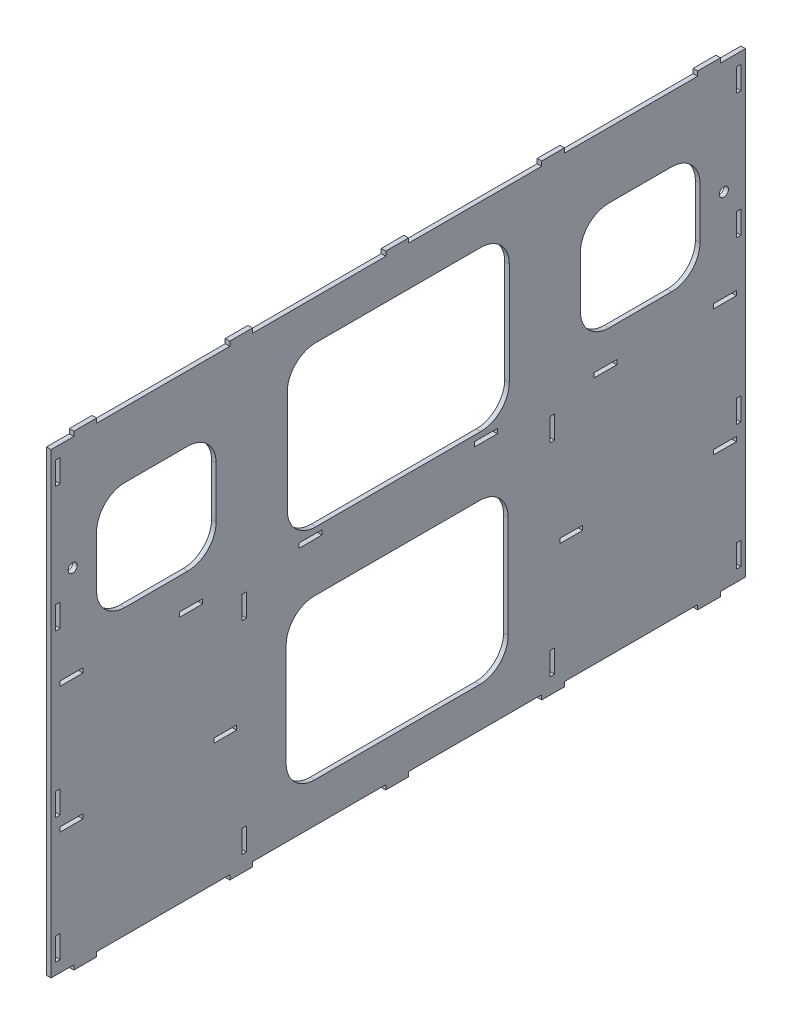
from build123d import *

# Parameters (mm, degrees)
SKETCH1_W           = 20
SKETCH1_H           = 4
SKETCH1_W_2         = 4
SKETCH1_H_2         = 20
BOSS_EXTRUDE1_DEPTH = 4
CUT_EXTRUDE1_DEPTH  = 10
SKETCH3_R           = 4
CUT_EXTRUDE2_DEPTH  = 10


with BuildPart() as part:
    # Sketch1 → Boss-Extrude1 (new body)
    with BuildSketch(Plane(origin=(0, 0, 0), x_dir=(0, 0, -1), z_dir=(1, 0, 0))):
        Polygon((-401.564712347, -166), (-381.564712347, -166), (-381.564712347, -170), (-361.564712347, -170), (-361.564712347, -166), (-244.564712347, -166), (-244.564712347, -170), (-224.564712347, -170), (-224.564712347, -166), (-107.564712347, -166), (-107.564712347, -170), (-87.564712347, -170), (-87.564712347, -166), (29.435287653, -166), (29.435287653, -170), (49.435287653, -170), (49.435287653, -166), (166.435287653, -166), (166.435287653, -170), (186.435287653, -170), (186.435287653, -166), (208.435287653, -166), (208.435287653, 236), (186.435287653, 236), (186.435287653, 240), (166.435287653, 240), (166.435287653, 236), (49.435287653, 236), (49.435287653, 240), (29.435287653, 240), (29.435287653, 236), (-87.564712347, 236), (-87.564712347, 240), (-107.564712347, 240), (-107.564712347, 236), (-224.564712347, 236), (-224.564712347, 240), (-244.564712347, 240), (-244.564712347, 236), (-361.564712347, 236), (-361.564712347, 240), (-381.564712347, 240), (-381.564712347, 236), (-401.564712347, 236), align=None)
        with Locations((190.435287653, -57)):
            Rectangle(SKETCH1_W, SKETCH1_H, mode=Mode.SUBTRACT)
        with Locations((38.825287653, 32)):
            Rectangle(SKETCH1_W_2, SKETCH1_H_2, mode=Mode.SUBTRACT)
        with Locations((38.825287653, -146)):
            Rectangle(SKETCH1_W_2, SKETCH1_H_2, mode=Mode.SUBTRACT)
        with Locations((-395.564712347, 216)):
            Rectangle(SKETCH1_W_2, SKETCH1_H_2, mode=Mode.SUBTRACT)
        with Locations((-395.564712347, 106)):
            Rectangle(SKETCH1_W_2, SKETCH1_H_2, mode=Mode.SUBTRACT)
        with Locations((-395.564712347, -36)):
            Rectangle(SKETCH1_W_2, SKETCH1_H_2, mode=Mode.SUBTRACT)
        with Locations((-395.564712347, -146)):
            Rectangle(SKETCH1_W_2, SKETCH1_H_2, mode=Mode.SUBTRACT)
        with Locations((202.435287653, 216)):
            Rectangle(SKETCH1_W_2, SKETCH1_H_2, mode=Mode.SUBTRACT)
        with Locations((202.435287653, 106)):
            Rectangle(SKETCH1_W_2, SKETCH1_H_2, mode=Mode.SUBTRACT)
        with Locations((202.435287653, -36)):
            Rectangle(SKETCH1_W_2, SKETCH1_H_2, mode=Mode.SUBTRACT)
        with Locations((202.435287653, -146)):
            Rectangle(SKETCH1_W_2, SKETCH1_H_2, mode=Mode.SUBTRACT)
        with Locations((190.435287653, 54)):
            Rectangle(SKETCH1_W, SKETCH1_H, mode=Mode.SUBTRACT)
        with Locations((-231.954712347, -146)):
            Rectangle(SKETCH1_W_2, SKETCH1_H_2, mode=Mode.SUBTRACT)
        with Locations((-231.954712347, 32)):
            Rectangle(SKETCH1_W_2, SKETCH1_H_2, mode=Mode.SUBTRACT)
        with Locations((-383.564712347, 54)):
            Rectangle(SKETCH1_W, SKETCH1_H, mode=Mode.SUBTRACT)
        with Locations((-278.564712347, 54)):
            Rectangle(SKETCH1_W, SKETCH1_H, mode=Mode.SUBTRACT)
        with Locations((-173.564712347, 54)):
            Rectangle(SKETCH1_W, SKETCH1_H, mode=Mode.SUBTRACT)
        with Locations((85.435287653, 54)):
            Rectangle(SKETCH1_W, SKETCH1_H, mode=Mode.SUBTRACT)
        with Locations((-19.564712347, 54)):
            Rectangle(SKETCH1_W, SKETCH1_H, mode=Mode.SUBTRACT)
        with Locations((-248.564712347, -57)):
            Rectangle(SKETCH1_W, SKETCH1_H, mode=Mode.SUBTRACT)
        with Locations((-383.564712347, -57)):
            Rectangle(SKETCH1_W, SKETCH1_H, mode=Mode.SUBTRACT)
        with Locations((55.435287653, -57)):
            Rectangle(SKETCH1_W, SKETCH1_H, mode=Mode.SUBTRACT)
    extrude(amount=BOSS_EXTRUDE1_DEPTH)

    # Sketch2 → Cut-Extrude1 (cut)
    with BuildSketch(Plane(origin=(4, 0, 0), x_dir=(0, 0, -1), z_dir=(1, 0, 0))):
        with BuildLine():
            Line((-170.064712347, 9), (-25.064712347, 9))
            ThreePointArc((-25.064712347, 9), (-7.387042818, 1.67766953), (-0.064712347, -16))
            Line((-0.064712347, -16), (-0.064712347, -106))
            ThreePointArc((-0.064712347, -106), (-7.387042818, -123.67766953), (-25.064712347, -131))
            Line((-25.064712347, -131), (-170.064712347, -131))
            ThreePointArc((-170.064712347, -131), (-187.742381877, -123.67766953), (-195.064712347, -106))
            Line((-195.064712347, -106), (-195.064712347, -16))
            ThreePointArc((-195.064712347, -16), (-187.742381877, 1.67766953), (-170.064712347, 9))
        make_face()
        with BuildLine():
            Line((-169.064712347, 201), (-24.064712347, 201))
            ThreePointArc((-24.064712347, 201), (-6.387042818, 193.67766953), (0.935287653, 176))
            Line((0.935287653, 176), (0.935287653, 86))
            ThreePointArc((0.935287653, 86), (-6.387042818, 68.32233047), (-24.064712347, 61))
            Line((-24.064712347, 61), (-169.064712347, 61))
            ThreePointArc((-169.064712347, 61), (-186.742381877, 68.32233047), (-194.064712347, 86))
            Line((-194.064712347, 86), (-194.064712347, 176))
            ThreePointArc((-194.064712347, 176), (-186.742381877, 193.67766953), (-169.064712347, 201))
        make_face()
        with BuildLine():
            Line((-336.564712347, 178.5), (-281.564712347, 178.5))
            ThreePointArc((-281.564712347, 178.5), (-263.887042818, 171.17766953), (-256.564712347, 153.5))
            Line((-256.564712347, 153.5), (-256.564712347, 108.5))
            ThreePointArc((-256.564712347, 108.5), (-263.887042818, 90.82233047), (-281.564712347, 83.5))
            Line((-281.564712347, 83.5), (-336.564712347, 83.5))
            ThreePointArc((-336.564712347, 83.5), (-354.242381877, 90.82233047), (-361.564712347, 108.5))
            Line((-361.564712347, 108.5), (-361.564712347, 153.5))
            ThreePointArc((-361.564712347, 153.5), (-354.242381877, 171.17766953), (-336.564712347, 178.5))
        make_face()
        with BuildLine():
            Line((88.435287653, 178.5), (143.435287653, 178.5))
            ThreePointArc((143.435287653, 178.5), (161.112957182, 171.17766953), (168.435287653, 153.5))
            Line((168.435287653, 153.5), (168.435287653, 108.5))
            ThreePointArc((168.435287653, 108.5), (161.112957182, 90.82233047), (143.435287653, 83.5))
            Line((143.435287653, 83.5), (88.435287653, 83.5))
            ThreePointArc((88.435287653, 83.5), (70.757618123, 90.82233047), (63.435287653, 108.5))
            Line((63.435287653, 108.5), (63.435287653, 153.5))
            ThreePointArc((63.435287653, 153.5), (70.757618123, 171.17766953), (88.435287653, 178.5))
        make_face()
    extrude(amount=-CUT_EXTRUDE1_DEPTH, mode=Mode.SUBTRACT)

    # Sketch3 → Cut-Extrude2 (cut)
    with BuildSketch(Plane(origin=(4, 0, 0), x_dir=(0, 0, -1), z_dir=(1, 0, 0))):
        with Locations((-382.564712347, 136.477800328)):
            Circle(SKETCH3_R)
        with Locations((189.435287653, 136.477800328)):
            Circle(SKETCH3_R)
    extrude(amount=-CUT_EXTRUDE2_DEPTH, mode=Mode.SUBTRACT)


solid = part.part
